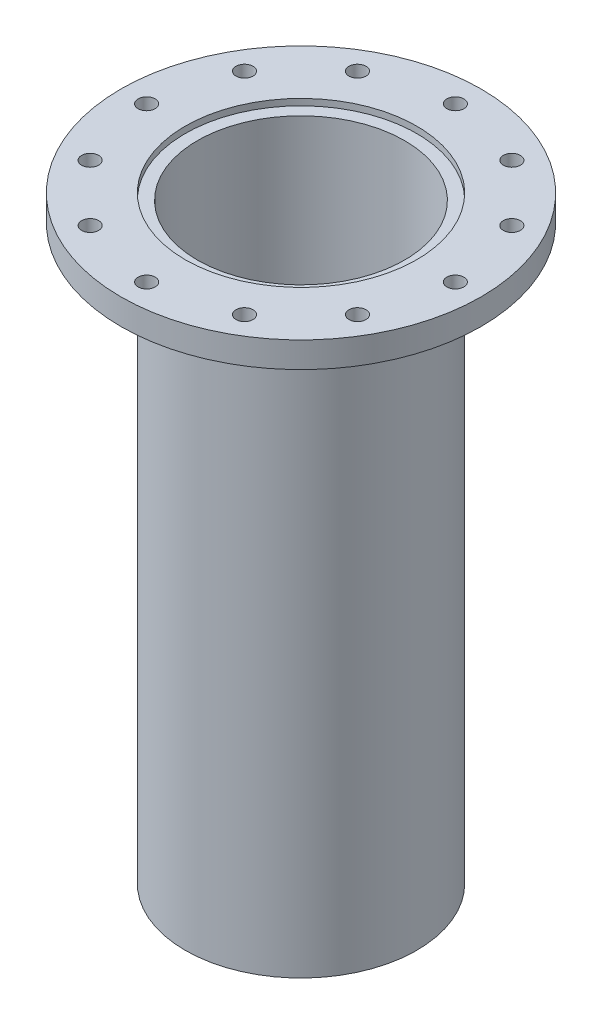
from build123d import *

# Parameters (mm, degrees)
F_5_16_CLEARANCE_HOLE1_D = 8.4328
CIRPATTERN1_COUNT        = 12


with BuildPart() as part:
    # Sketch1 → Revolve1 (revolve)
    with BuildSketch(Plane.XY):
        Polygon((-57.15, 0), (-88.9, 0), (-88.9, -12.7), (-57.15, -12.7), (-57.15, -295.275), (-51.1302, -295.275), (-51.1302, -3.175), (-57.15, -3.175), align=None)
    revolve(axis=Axis((0, 0, 0), (0, -1, 0)))

    # 5/16 Clearance Hole1 (through all)
    with Locations(Plane(origin=(0, 0, 0), x_dir=(1, 0, 0), z_dir=(0, 1, 0))):
        with Locations((-76.2, 0)):
            f_5_16_clearance_hole1 = Hole(F_5_16_CLEARANCE_HOLE1_D / 2)

    # CirPattern1: 5/16 Clearance Hole1 ×12 about axis
    cirpattern1_axis = Axis((0, 0, 0), (0, 1, 0))
    for i in range(1, CIRPATTERN1_COUNT):
        add(f_5_16_clearance_hole1.rotate(cirpattern1_axis, i * 360 / CIRPATTERN1_COUNT), mode=Mode.SUBTRACT)


solid = part.part
